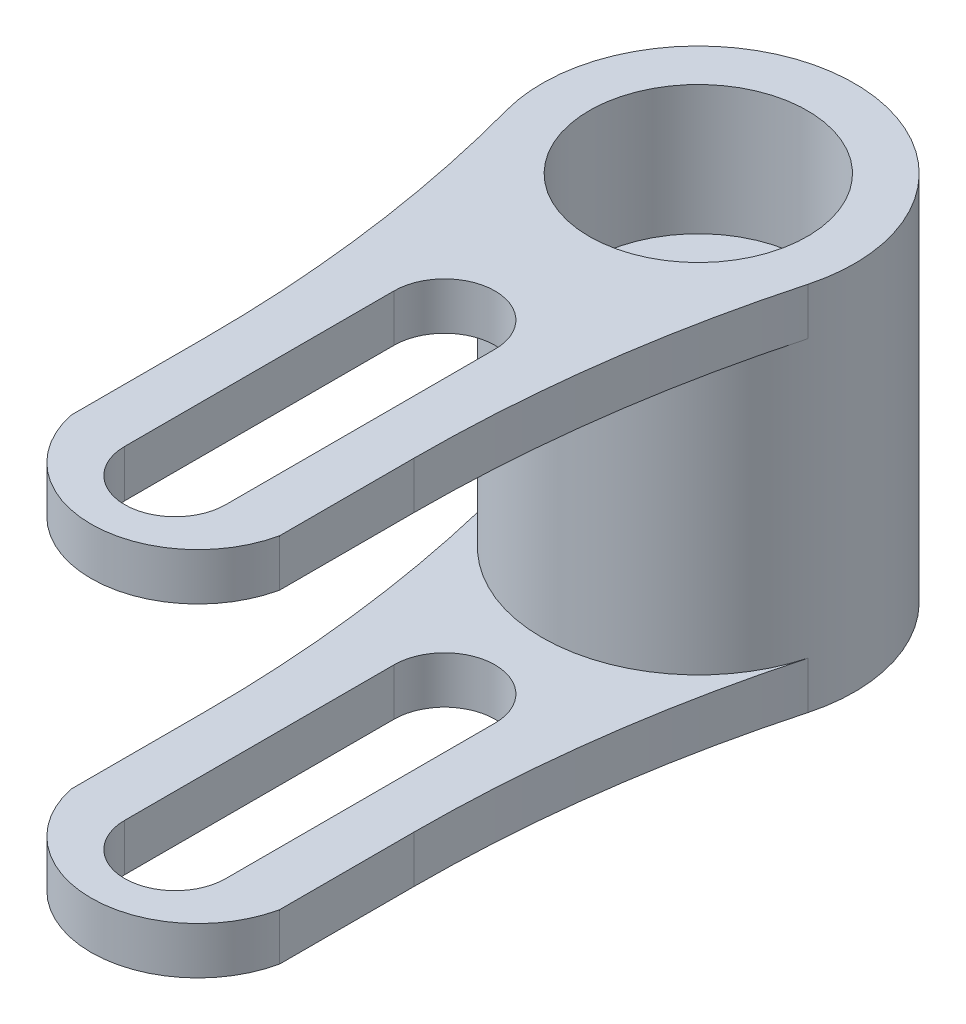
from build123d import *

# Parameters (mm, degrees)
SKETCH1_R           = 5.8
SKETCH1_R_2         = 4.05
BOSS_EXTRUDE1_DEPTH = 6.8875
CUT_EXTRUDE1_START  = -5.1375
CUT_EXTRUDE1_DEPTH  = 10.274999888
CUT_EXTRUDE2_START  = 6.8875
SKETCH1_5_R         = 4.05
CUT_EXTRUDE2_DEPTH  = 4.8
CUT_EXTRUDE3_DEPTH  = 28.681774239


with BuildPart() as part:
    # Sketch1 → Boss-Extrude1 (new, symmetric)
    with BuildSketch(Plane(origin=(0, 0, 0), x_dir=(1, 0, 0), z_dir=(0, 1, 0))):
        with BuildLine():
            ThreePointArc((-5.597034746, -1.520921448), (-4.307408497, -7.915763352), (-3.875, -14.425))
            Line((-3.875, -14.425), (-3.875, -19.425))
            ThreePointArc((-3.875, -19.425), (0, -23.3), (3.875, -19.425))
            Line((3.875, -19.425), (3.875, -14.425))
            ThreePointArc((3.875, -14.425), (4.307408497, -7.915763352), (5.597034746, -1.520921448))
            ThreePointArc((5.597034746, -1.520921448), (0, -5.8), (-5.597034746, -1.520921448))
        make_face()
        with BuildLine():
            ThreePointArc((-1.875, -9.425), (0, -7.55), (1.875, -9.425))
            Line((1.875, -9.425), (1.875, -19.425))
            ThreePointArc((1.875, -19.425), (0, -21.3), (-1.875, -19.425))
            Line((-1.875, -19.425), (-1.875, -9.425))
        make_face(mode=Mode.SUBTRACT)
        Circle(SKETCH1_R)
        Circle(SKETCH1_R_2, mode=Mode.SUBTRACT)
        Circle(SKETCH1_R_2)
    extrude(amount=BOSS_EXTRUDE1_DEPTH, both=True)

    # Sketch1_4 → Cut-Extrude1 (cut)
    with BuildSketch(Plane(origin=(0, 0, 0), x_dir=(1, 0, 0), z_dir=(0, 1, 0)).offset(CUT_EXTRUDE1_START)):
        with BuildLine():
            ThreePointArc((-5.597034746, -1.520921448), (-4.307408497, -7.915763352), (-3.875, -14.425))
            Line((-3.875, -14.425), (-3.875, -19.425))
            ThreePointArc((-3.875, -19.425), (0, -23.3), (3.875, -19.425))
            Line((3.875, -19.425), (3.875, -14.425))
            ThreePointArc((3.875, -14.425), (4.307408497, -7.915763352), (5.597034746, -1.520921448))
            ThreePointArc((5.597034746, -1.520921448), (0, -5.8), (-5.597034746, -1.520921448))
        make_face()
        with BuildLine():
            ThreePointArc((-1.875, -9.425), (0, -7.55), (1.875, -9.425))
            Line((1.875, -9.425), (1.875, -19.425))
            ThreePointArc((1.875, -19.425), (0, -21.3), (-1.875, -19.425))
            Line((-1.875, -19.425), (-1.875, -9.425))
        make_face(mode=Mode.SUBTRACT)
    extrude(amount=CUT_EXTRUDE1_DEPTH, mode=Mode.SUBTRACT)

    # Sketch1_5 → Cut-Extrude2 (cut)
    with BuildSketch(Plane(origin=(0, 0, 0), x_dir=(1, 0, 0), z_dir=(0, 1, 0)).offset(CUT_EXTRUDE2_START)):
        with Locations(Location((0, 0, 0), (0, 0, 270))):
            Circle(SKETCH1_5_R)
    extrude(amount=-CUT_EXTRUDE2_DEPTH, mode=Mode.SUBTRACT)

    # Sketch4 → Cut-Extrude3 (cut, through all)
    with BuildSketch(Plane.XZ.offset(6.8875)):
        with BuildLine():
            ThreePointArc((-3.875, 19.425), (0, 22.55), (3.875, 19.425))
            ThreePointArc((3.875, 19.425), (0, 23.3), (-3.875, 19.425))
        make_face()
    extrude(amount=-CUT_EXTRUDE3_DEPTH, mode=Mode.SUBTRACT)


solid = part.part
